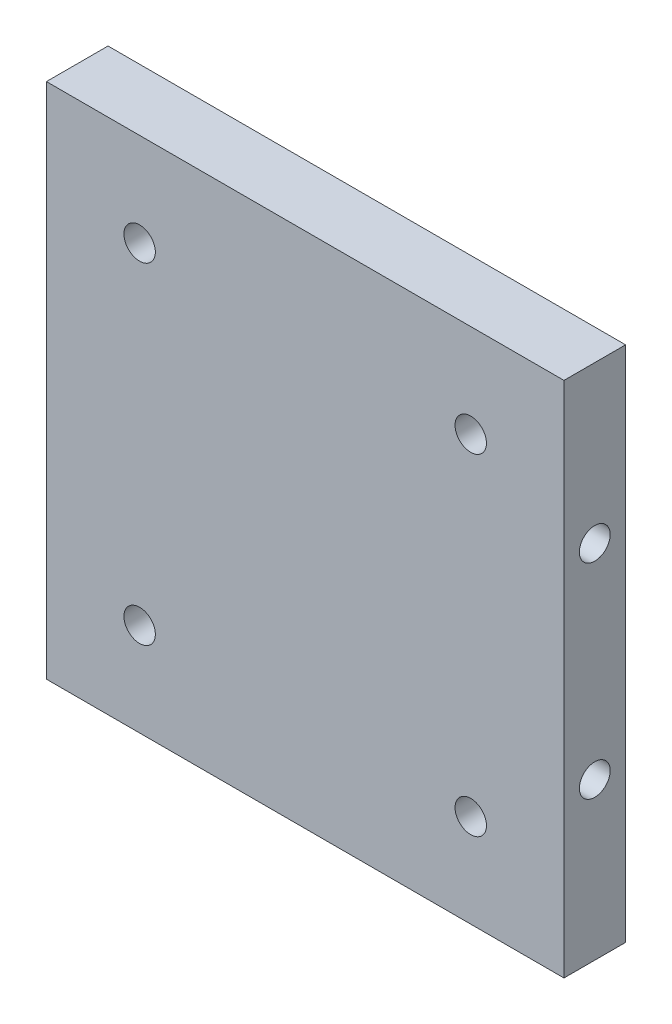
from build123d import *

# Parameters (mm, degrees)
SKETCH_1_W          = 42
SKETCH_1_H          = 42
EXTRUDE_1_DEPTH     = 5
SKETCH_2_R          = 1.275
CUT_EXTRUDE_1_DEPTH = 6
HOLE_WIZARD_M3_1_D  = 2.5


with BuildPart() as part:
    # 草图1 → 凸台-拉伸1 (new body)
    with BuildSketch(Plane.XY):
        Rectangle(SKETCH_1_W, SKETCH_1_H)
    extrude(amount=EXTRUDE_1_DEPTH)

    # 草图2 → 切除-拉伸1 (cut, through all)
    with BuildSketch(Plane.XY.offset(5)):
        with Locations((13.435028843, 13.435028843)):
            Circle(SKETCH_2_R)
        with Locations((13.435028843, -13.435028843)):
            Circle(SKETCH_2_R)
        with Locations((-13.435028843, -13.435028843)):
            Circle(SKETCH_2_R)
        with Locations((-13.435028843, 13.435028843)):
            Circle(SKETCH_2_R)
    extrude(amount=-CUT_EXTRUDE_1_DEPTH, mode=Mode.SUBTRACT)

    # M3 螺纹孔1 (through all)
    with Locations(Plane(origin=(21, 0, 0), x_dir=(0, 0, -1), z_dir=(1, 0, 0))):
        with Locations((-2.5, 8.3)):
            hole_wizard_m3_1 = Hole(HOLE_WIZARD_M3_1_D / 2)

    # 镜向1: M3 螺纹孔1 across plane
    add(hole_wizard_m3_1.mirror(Plane.ZX), mode=Mode.SUBTRACT)


solid = part.part
